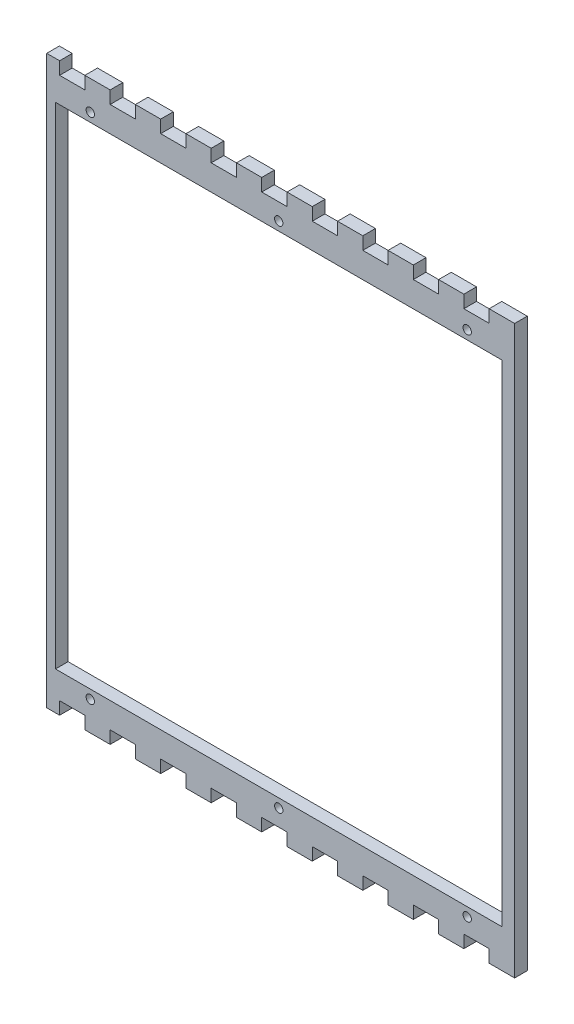
from build123d import *

# Parameters (mm, degrees)
BOSS_EXTRUDE1_DEPTH                               = 5.715
SKETCH1_W                                         = 202
SKETCH1_H                                         = 222
CUT_EXTRUDE1_DEPTH                                = 6.715
CSK_FOR_6_FLAT_HEAD_SOCKET_CAP_SCREW1_D           = 3.7973
CSK_FOR_6_FLAT_HEAD_SOCKET_CAP_SCREW1_DEPTH       = 20
CSK_FOR_6_FLAT_HEAD_SOCKET_CAP_SCREW1_CSINK_D     = 7.7978
CSK_FOR_6_FLAT_HEAD_SOCKET_CAP_SCREW1_CSINK_ANGLE = 82
CSK_FOR_6_FLAT_HEAD_SOCKET_CAP_SCREW1_TIP         = 1.140824014


with BuildPart() as part:
    # Model → Boss-Extrude1 (new body)
    with BuildSketch(Plane.XY):
        Polygon((1024.07974, 23.2006394), (1029.90396, 23.2006394), (1029.90396, 28.91536), (1041.33396, 28.91536), (1041.33396, 23.2006394), (1052.76396, 23.2006394), (1052.76396, 28.91536), (1064.19396, 28.91536), (1064.19396, 23.2006394), (1075.62396, 23.2006394), (1075.62396, 28.91536), (1087.05396, 28.91536), (1087.05396, 23.2006394), (1098.48396, 23.2006394), (1098.48396, 28.91536), (1109.91396, 28.91536), (1109.91396, 23.2006394), (1121.34396, 23.2006394), (1121.34396, 28.91536), (1132.77396, 28.91536), (1132.77396, 23.2006394), (1144.20396, 23.2006394), (1144.20396, 28.91536), (1155.63396, 28.91536), (1155.63396, 23.2006394), (1167.06396, 23.2006394), (1167.06396, 28.91536), (1178.49396, 28.91536), (1178.49396, 23.2006394), (1189.92396, 23.2006394), (1189.92396, 28.91536), (1201.35396, 28.91536), (1201.35396, 23.2006394), (1212.78396, 23.2006394), (1212.78396, 28.91536), (1224.21396, 28.91536), (1224.21396, 23.2006394), (1235.75318, 23.2006394), (1235.75318, 279.63114), (1224.21396, 279.63114), (1224.21396, 273.91614), (1212.78396, 273.91614), (1212.78396, 279.63114), (1201.35396, 279.63114), (1201.35396, 273.91614), (1189.92396, 273.91614), (1189.92396, 279.63114), (1178.49396, 279.63114), (1178.49396, 273.91614), (1167.06396, 273.91614), (1167.06396, 279.63114), (1155.63396, 279.63114), (1155.63396, 273.91614), (1144.20396, 273.91614), (1144.20396, 279.63114), (1132.77396, 279.63114), (1132.77396, 273.91614), (1121.34396, 273.91614), (1121.34396, 279.63114), (1109.91396, 279.63114), (1109.91396, 273.91614), (1098.48396, 273.91614), (1098.48396, 279.63114), (1087.05396, 279.63114), (1087.05396, 273.91614), (1075.62396, 273.91614), (1075.62396, 279.63114), (1064.19396, 279.63114), (1064.19396, 273.91614), (1052.76396, 273.91614), (1052.76396, 279.63114), (1041.33396, 279.63114), (1041.33396, 273.91614), (1029.90396, 273.91614), (1029.90396, 279.63114), (1024.07974, 279.63114), align=None)
    extrude(amount=BOSS_EXTRUDE1_DEPTH)

    # Sketch1 → Cut-Extrude1 (cut, through all)
    with BuildSketch(Plane(origin=(0, 0, 0), x_dir=(-1, 0, 0), z_dir=(0, 0, -1))):
        with Locations((-1129.03818, 151.41575)):
            Rectangle(SKETCH1_W, SKETCH1_H)
    extrude(amount=-CUT_EXTRUDE1_DEPTH, mode=Mode.SUBTRACT)

    # CSK for #6 Flat Head Socket Cap Screw1
    with Locations(Plane(origin=(1095.03845, 151.41575, 0), x_dir=(-1, 0, 0), z_dir=(0, 0, -1))):
        with Locations((-119.24973, 115), (-33.99973, 115), (51.25027, 115), (51.25027, -115), (-33.99973, -115), (-119.24973, -115)):
            CounterSinkHole(CSK_FOR_6_FLAT_HEAD_SOCKET_CAP_SCREW1_D / 2, CSK_FOR_6_FLAT_HEAD_SOCKET_CAP_SCREW1_CSINK_D / 2, depth=CSK_FOR_6_FLAT_HEAD_SOCKET_CAP_SCREW1_DEPTH, counter_sink_angle=CSK_FOR_6_FLAT_HEAD_SOCKET_CAP_SCREW1_CSINK_ANGLE)
            with Locations((0, 0, -(CSK_FOR_6_FLAT_HEAD_SOCKET_CAP_SCREW1_DEPTH + CSK_FOR_6_FLAT_HEAD_SOCKET_CAP_SCREW1_TIP / 2))):  # 118° drill point
                Cone(0, CSK_FOR_6_FLAT_HEAD_SOCKET_CAP_SCREW1_D / 2, CSK_FOR_6_FLAT_HEAD_SOCKET_CAP_SCREW1_TIP, mode=Mode.SUBTRACT)


solid = part.part
